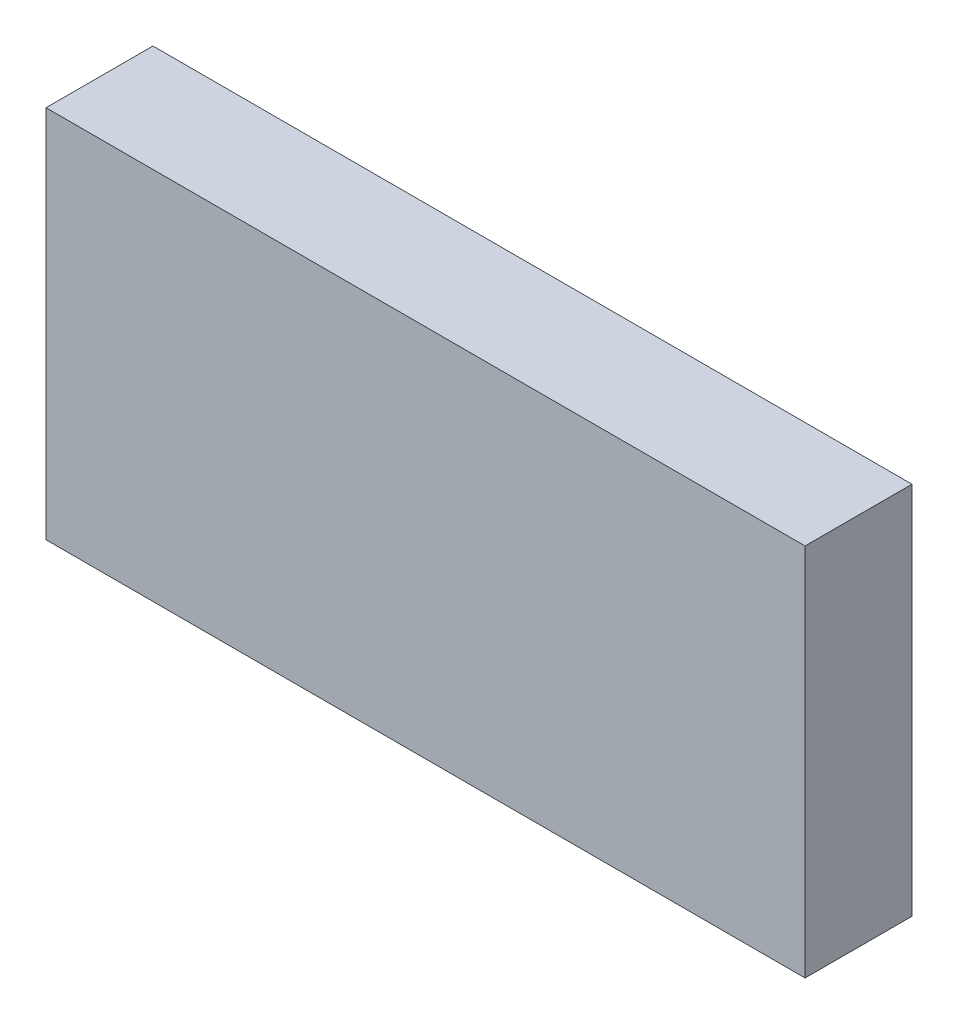
from build123d import *

# Parameters (mm, degrees)
SKETCH1_W               = 7.1
SKETCH1_H               = 3.5
COMPONENT_OUTLINE_DEPTH = 1


with BuildPart() as part:
    # Sketch1 → Component_Outline (new body)
    with BuildSketch(Plane.XY):
        Rectangle(SKETCH1_W, SKETCH1_H)
    extrude(amount=COMPONENT_OUTLINE_DEPTH)


solid = part.part
